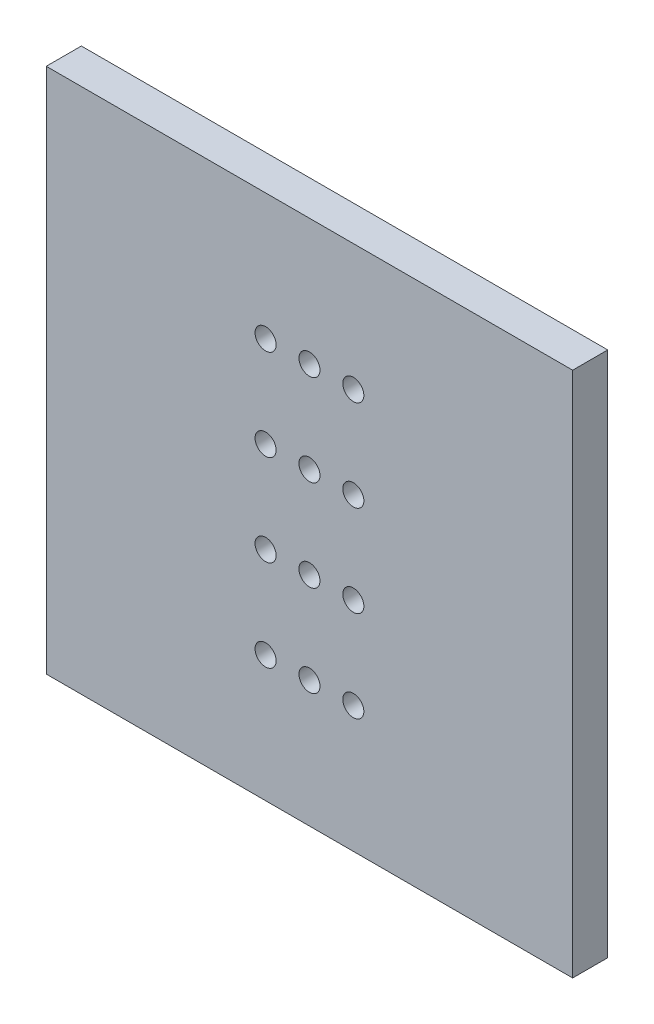
from build123d import *

# Parameters (mm, degrees)
ESQUISSE1_W            = 30
ESQUISSE1_H            = 30
BASE_PLATE_DEPTH       = 2
SKETCH_PERFORATIONS_R  = 0.6
CUT_PERFORATIONS_DEPTH = 10


with BuildPart() as part:
    # Esquisse1 → Base_Plate (new body)
    with BuildSketch(Plane.XY):
        Rectangle(ESQUISSE1_W, ESQUISSE1_H)
    extrude(amount=BASE_PLATE_DEPTH)

    # Sketch_Perforations → Cut_Perforations (cut)
    with BuildSketch(Plane.XY.offset(2)):
        with Locations((-2.5, -7.8)):
            Circle(SKETCH_PERFORATIONS_R)
        with Locations((-2.5, -2.6)):
            Circle(SKETCH_PERFORATIONS_R)
        with Locations((-2.5, 2.6)):
            Circle(SKETCH_PERFORATIONS_R)
        with Locations((-2.5, 7.8)):
            Circle(SKETCH_PERFORATIONS_R)
        with Locations((0, -7.8)):
            Circle(SKETCH_PERFORATIONS_R)
        with Locations((0, -2.6)):
            Circle(SKETCH_PERFORATIONS_R)
        with Locations((0, 2.6)):
            Circle(SKETCH_PERFORATIONS_R)
        with Locations((0, 7.8)):
            Circle(SKETCH_PERFORATIONS_R)
        with Locations((2.5, -7.8)):
            Circle(SKETCH_PERFORATIONS_R)
        with Locations((2.5, -2.6)):
            Circle(SKETCH_PERFORATIONS_R)
        with Locations((2.5, 2.6)):
            Circle(SKETCH_PERFORATIONS_R)
        with Locations((2.5, 7.8)):
            Circle(SKETCH_PERFORATIONS_R)
    extrude(amount=-CUT_PERFORATIONS_DEPTH, mode=Mode.SUBTRACT)


solid = part.part
